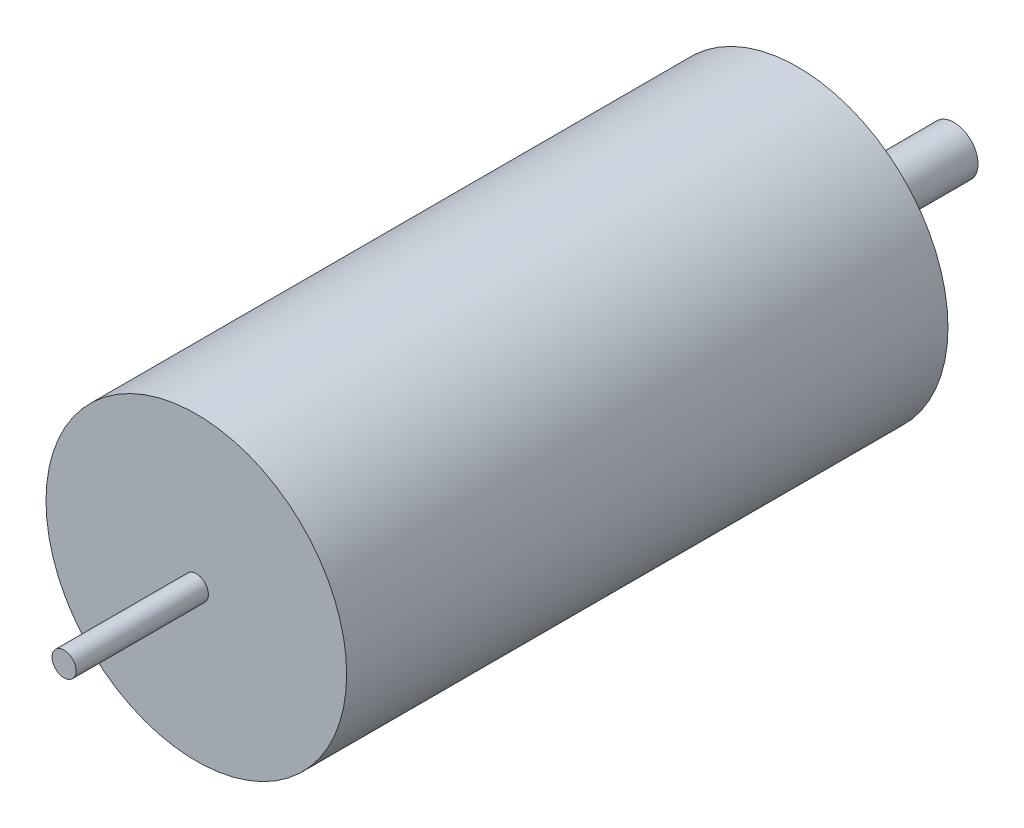
from build123d import *

# Parameters (mm, degrees)
SKETCH1_R           = 12.5
BOSS_EXTRUDE1_DEPTH = 50
SKETCH2_R           = 3.5
BOSS_EXTRUDE2_DEPTH = 2
SKETCH3_R           = 2
BOSS_EXTRUDE3_DEPTH = 11
SKETCH4_R           = 1.5
CUT_EXTRUDE1_DEPTH  = 5
SKETCH5_R           = 1
BOSS_EXTRUDE4_DEPTH = 11


with BuildPart() as part:
    # Sketch1 → Boss-Extrude1 (new body)
    with BuildSketch(Plane.XY):
        Circle(SKETCH1_R)
    extrude(amount=BOSS_EXTRUDE1_DEPTH)

    # Sketch2 → Boss-Extrude2 (add)
    with BuildSketch(Plane(origin=(0, 0, 0), x_dir=(-1, 0, 0), z_dir=(0, 0, -1))):
        Circle(SKETCH2_R)
    extrude(amount=BOSS_EXTRUDE2_DEPTH)

    # Sketch3 → Boss-Extrude3 (add)
    with BuildSketch(Plane(origin=(0, 0, -2), x_dir=(-1, 0, 0), z_dir=(0, 0, -1))):
        Circle(SKETCH3_R)
    extrude(amount=BOSS_EXTRUDE3_DEPTH)

    # Sketch4 → Cut-Extrude1 (cut)
    with BuildSketch(Plane(origin=(0, 0, 0), x_dir=(-1, 0, 0), z_dir=(0, 0, -1))):
        with Locations((-8.5, 0)):
            Circle(SKETCH4_R)
        with Locations((8.5, 0)):
            Circle(SKETCH4_R)
    extrude(amount=-CUT_EXTRUDE1_DEPTH, mode=Mode.SUBTRACT)

    # Sketch5 → Boss-Extrude4 (add)
    with BuildSketch(Plane.XY.offset(50)):
        Circle(SKETCH5_R)
    extrude(amount=BOSS_EXTRUDE4_DEPTH)


solid = part.part
